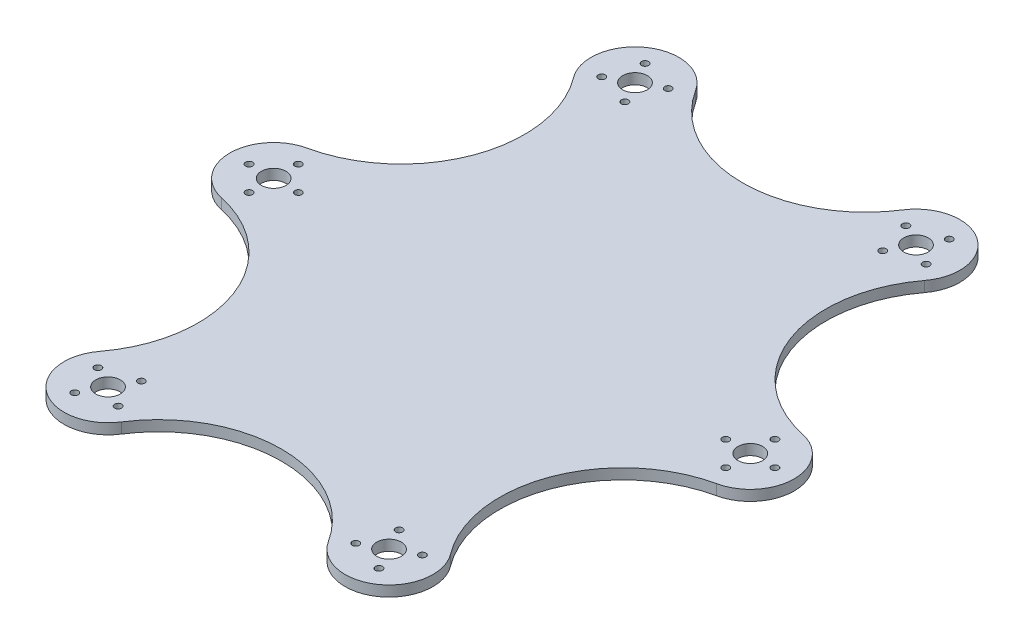
from build123d import *

# Parameters (mm, degrees)
SKETCH2_R           = 3.5
SKETCH2_R_2         = 1
BOSS_EXTRUDE1_DEPTH = 3


with BuildPart() as part:
    # Sketch2 → Boss-Extrude1 (new body)
    with BuildSketch(Plane(origin=(0, 0, 0), x_dir=(1, 0, 0), z_dir=(0, 1, 0))):
        with BuildLine():
            ThreePointArc((-29.473684211, 81.741414978), (-47.137131817, 85.262131817), (-49.983079412, 67.477492077))
            ThreePointArc((-49.983079412, 67.477492077), (-45.123201765, 34.234985347), (-70.495895485, 12.214334182))
            ThreePointArc((-70.495895485, 12.214334182), (-80.338821814, 0), (-70.495895485, -12.214334182))
            ThreePointArc((-70.495895485, -12.214334182), (-45.123201765, -34.234985347), (-49.983079412, -67.477492077))
            ThreePointArc((-49.983079412, -67.477492077), (-47.137131817, -85.262131817), (-29.473684211, -81.741414978))
            ThreePointArc((-29.473684211, -81.741414978), (0, -65.617376915), (29.473684211, -81.741414978))
            ThreePointArc((29.473684211, -81.741414978), (47.137131817, -85.262131817), (49.983079412, -67.477492077))
            ThreePointArc((49.983079412, -67.477492077), (45.123201765, -34.234985347), (70.495895485, -12.214334182))
            ThreePointArc((70.495895485, -12.214334182), (80.338821814, 0), (70.495895485, 12.214334182))
            ThreePointArc((70.495895485, 12.214334182), (45.123201765, 34.234985347), (49.983079412, 67.477492077))
            ThreePointArc((49.983079412, 67.477492077), (47.137131817, 85.262131817), (29.473684211, 81.741414978))
            ThreePointArc((29.473684211, 81.741414978), (0, 65.617376915), (-29.473684211, 81.741414978))
        make_face()
        with Locations((-40, 75)):
            Circle(SKETCH2_R, mode=Mode.SUBTRACT)
        with Locations((-67.838821814, 0)):
            Circle(SKETCH2_R, mode=Mode.SUBTRACT)
        with Locations((-40, -75)):
            Circle(SKETCH2_R, mode=Mode.SUBTRACT)
        with Locations((40, -75)):
            Circle(SKETCH2_R, mode=Mode.SUBTRACT)
        with Locations((67.838821814, 0)):
            Circle(SKETCH2_R, mode=Mode.SUBTRACT)
        with Locations((40, 75)):
            Circle(SKETCH2_R, mode=Mode.SUBTRACT)
        with Locations((-36.705882353, 68.823529412)):
            Circle(SKETCH2_R_2, mode=Mode.SUBTRACT)
        with Locations((-33.823529412, 78.294117647)):
            Circle(SKETCH2_R_2, mode=Mode.SUBTRACT)
        with Locations((-43.294117647, 81.176470588)):
            Circle(SKETCH2_R_2, mode=Mode.SUBTRACT)
        with Locations((-46.176470588, 71.705882353)):
            Circle(SKETCH2_R_2, mode=Mode.SUBTRACT)
        with Locations((-36.705882353, -68.823529412)):
            Circle(SKETCH2_R_2, mode=Mode.SUBTRACT)
        with Locations((-33.823529412, -78.294117647)):
            Circle(SKETCH2_R_2, mode=Mode.SUBTRACT)
        with Locations((-43.294117647, -81.176470588)):
            Circle(SKETCH2_R_2, mode=Mode.SUBTRACT)
        with Locations((-46.176470588, -71.705882353)):
            Circle(SKETCH2_R_2, mode=Mode.SUBTRACT)
        with Locations((-60.838821814, 0)):
            Circle(SKETCH2_R_2, mode=Mode.SUBTRACT)
        with Locations((-67.838821814, 7)):
            Circle(SKETCH2_R_2, mode=Mode.SUBTRACT)
        with Locations((-67.838821814, -7)):
            Circle(SKETCH2_R_2, mode=Mode.SUBTRACT)
        with Locations((-74.838821814, 0)):
            Circle(SKETCH2_R_2, mode=Mode.SUBTRACT)
        with Locations((43.294117647, -81.176470588)):
            Circle(SKETCH2_R_2, mode=Mode.SUBTRACT)
        with Locations((33.823529412, -78.294117647)):
            Circle(SKETCH2_R_2, mode=Mode.SUBTRACT)
        with Locations((46.176470588, -71.705882353)):
            Circle(SKETCH2_R_2, mode=Mode.SUBTRACT)
        with Locations((36.705882353, -68.823529412)):
            Circle(SKETCH2_R_2, mode=Mode.SUBTRACT)
        with Locations((67.838821814, -7)):
            Circle(SKETCH2_R_2, mode=Mode.SUBTRACT)
        with Locations((60.838821814, 0)):
            Circle(SKETCH2_R_2, mode=Mode.SUBTRACT)
        with Locations((74.838821814, 0)):
            Circle(SKETCH2_R_2, mode=Mode.SUBTRACT)
        with Locations((67.838821814, 7)):
            Circle(SKETCH2_R_2, mode=Mode.SUBTRACT)
        with Locations((36.705882353, 68.823529412)):
            Circle(SKETCH2_R_2, mode=Mode.SUBTRACT)
        with Locations((46.176470588, 71.705882353)):
            Circle(SKETCH2_R_2, mode=Mode.SUBTRACT)
        with Locations((33.823529412, 78.294117647)):
            Circle(SKETCH2_R_2, mode=Mode.SUBTRACT)
        with Locations((43.294117647, 81.176470588)):
            Circle(SKETCH2_R_2, mode=Mode.SUBTRACT)
    extrude(amount=BOSS_EXTRUDE1_DEPTH)


solid = part.part
